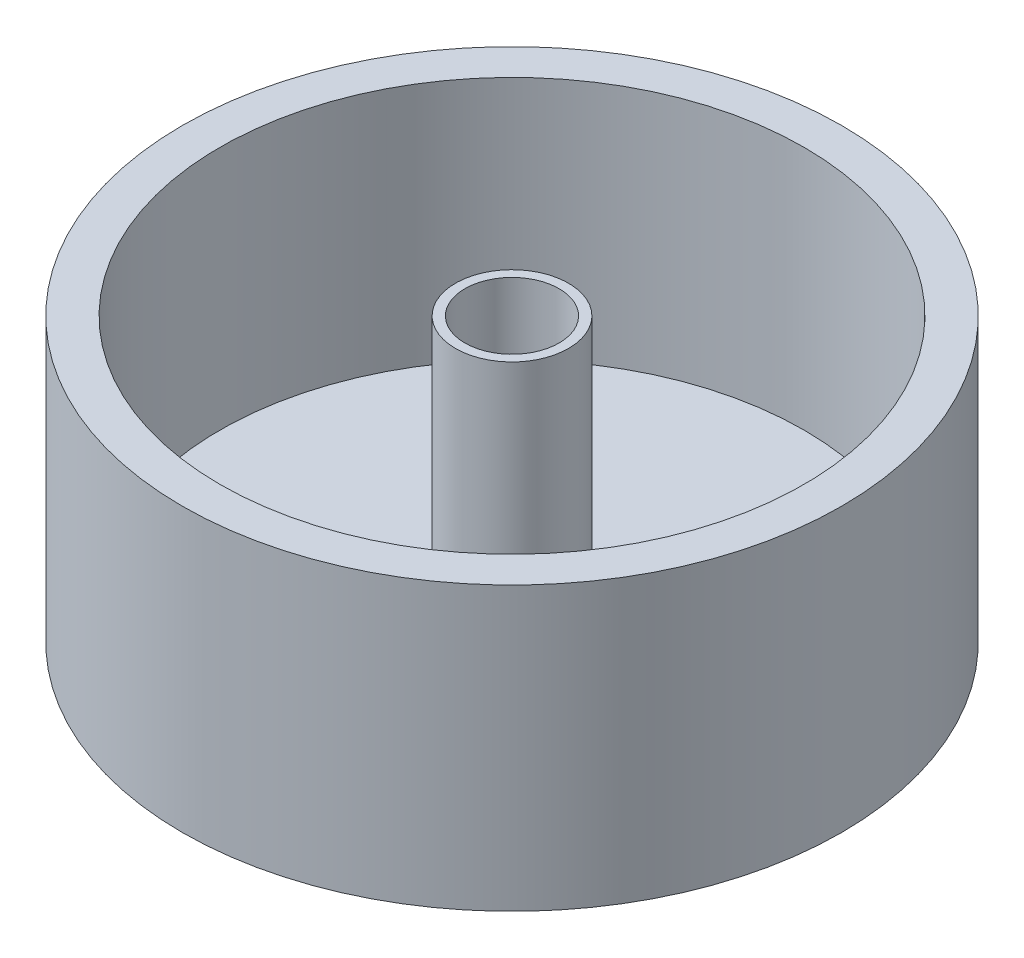
from build123d import *

# Parameters (mm, degrees)
ESBO_O1_R                  = 175
RESSALTO_EXTRUS_O1_DEPTH   = 20
ESBO_O3_R                  = 175
ESBO_O3_R_2                = 155
RESSALTO_EXTRUS_O3_DEPTH   = 130
ESBO_O4_R                  = 25
CORTE_EXTRUS_O1_DEPTH      = 131
CORTE_EXTRUS_O1_DEPTH_BACK = 21
ESBO_O5_R                  = 30
ESBO_O5_R_2                = 25
RESSALTO_EXTRUS_O4_DEPTH   = 130


with BuildPart() as part:
    # Esboço1 → Ressalto-extrusão1 (new body)
    with BuildSketch(Plane(origin=(0, 0, 0), x_dir=(1, 0, 0), z_dir=(0, 1, 0))):
        Circle(ESBO_O1_R)
    extrude(amount=RESSALTO_EXTRUS_O1_DEPTH)

    # Esboço3 → Ressalto-extrusão3 (add)
    with BuildSketch(Plane(origin=(0, 20, 0), x_dir=(1, 0, 0), z_dir=(0, 1, 0))):
        Circle(ESBO_O3_R)
        Circle(ESBO_O3_R_2, mode=Mode.SUBTRACT)
    extrude(amount=RESSALTO_EXTRUS_O3_DEPTH)

    # Esboço4 → Corte-extrusão1 (cut, two sides)
    with BuildSketch(Plane(origin=(0, 20, 0), x_dir=(1, 0, 0), z_dir=(0, 1, 0))) as corte_extrus_o1_sk:
        Circle(ESBO_O4_R)
    extrude(amount=CORTE_EXTRUS_O1_DEPTH, mode=Mode.SUBTRACT)
    extrude(corte_extrus_o1_sk.sketch, amount=-CORTE_EXTRUS_O1_DEPTH_BACK, mode=Mode.SUBTRACT)

    # Esboço5 → Ressalto-extrusão4 (add, through all)
    with BuildSketch(Plane(origin=(0, 20, 0), x_dir=(1, 0, 0), z_dir=(0, 1, 0))):
        Circle(ESBO_O5_R)
        Circle(ESBO_O5_R_2, mode=Mode.SUBTRACT)
    extrude(amount=RESSALTO_EXTRUS_O4_DEPTH)


solid = part.part
